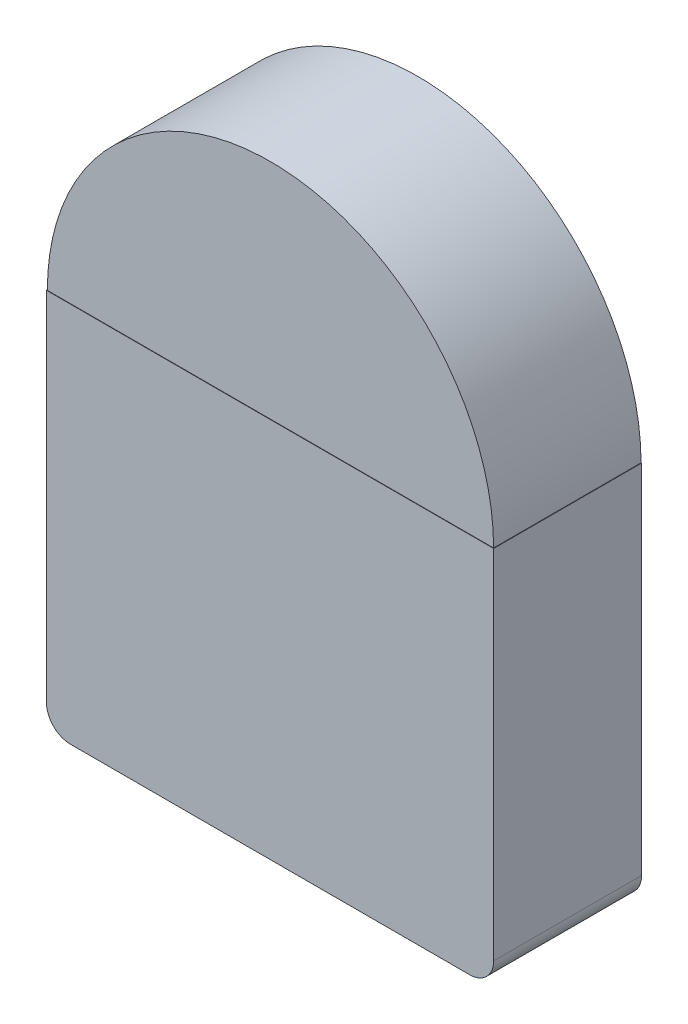
from build123d import *

# Parameters (mm, degrees)
SKETCH_1_W          = 9.29
SKETCH_1_H          = 1.5
REVOLVE_1_ANGLE     = 180
EXTRUDE_1_DEPTH     = 4.65
SKETCH_3_W          = 18.62
SKETCH_3_H          = 6.156693915
EXTRUDE_2_DEPTH     = 15.87
FILLET_1_R          = 1
CUT_EXTRUDE_1_DEPTH = 0.01


with BuildPart() as part:
    # 草图1 → 旋转1 (revolve)
    with BuildSketch(Plane.XZ):
        with Locations((-4.646272468, 0.75)):
            Rectangle(SKETCH_1_W, SKETCH_1_H)
    revolve(axis=Axis((-0.001272468, 0, 0), (0, 0, -1)), revolution_arc=REVOLVE_1_ANGLE)

    # 草图2 → 凸台-拉伸1 (add)
    with BuildSketch(Plane.XY.offset(1.5)):
        with BuildLine():
            Line((-9.291272468, 0), (9.288727532, 0))
            ThreePointArc((9.288727532, 0), (-0.001272468, 9.29), (-9.291272468, 0))
        make_face()
    extrude(amount=EXTRUDE_1_DEPTH)

    # 草图3 → 凸台-拉伸2 (add)
    with BuildSketch(Plane.XZ):
        with Locations((-0.001272468, 3.078346957)):
            Rectangle(SKETCH_3_W, SKETCH_3_H)
    extrude(amount=EXTRUDE_2_DEPTH)

    # 圆角1
    fillet_1_edges = [part.edges().sort_by_distance(p)[0] for p in [
        (9.308727532, -15.87, 3.078346957),
        (-9.311272468, -15.87, 3.078346957),
    ]]
    fillet(fillet_1_edges, radius=FILLET_1_R)

    # 草图4 → 切除-拉伸1 (cut)
    with BuildSketch(Plane.XY.offset(6.15)):
        with BuildLine():
            Line((-9.291272468, 0), (9.288727532, 0))
            ThreePointArc((9.288727532, 0), (-0.001272468, 9.29), (-9.291272468, 0))
        make_face()
    extrude(amount=-CUT_EXTRUDE_1_DEPTH, mode=Mode.SUBTRACT)


solid = part.part
